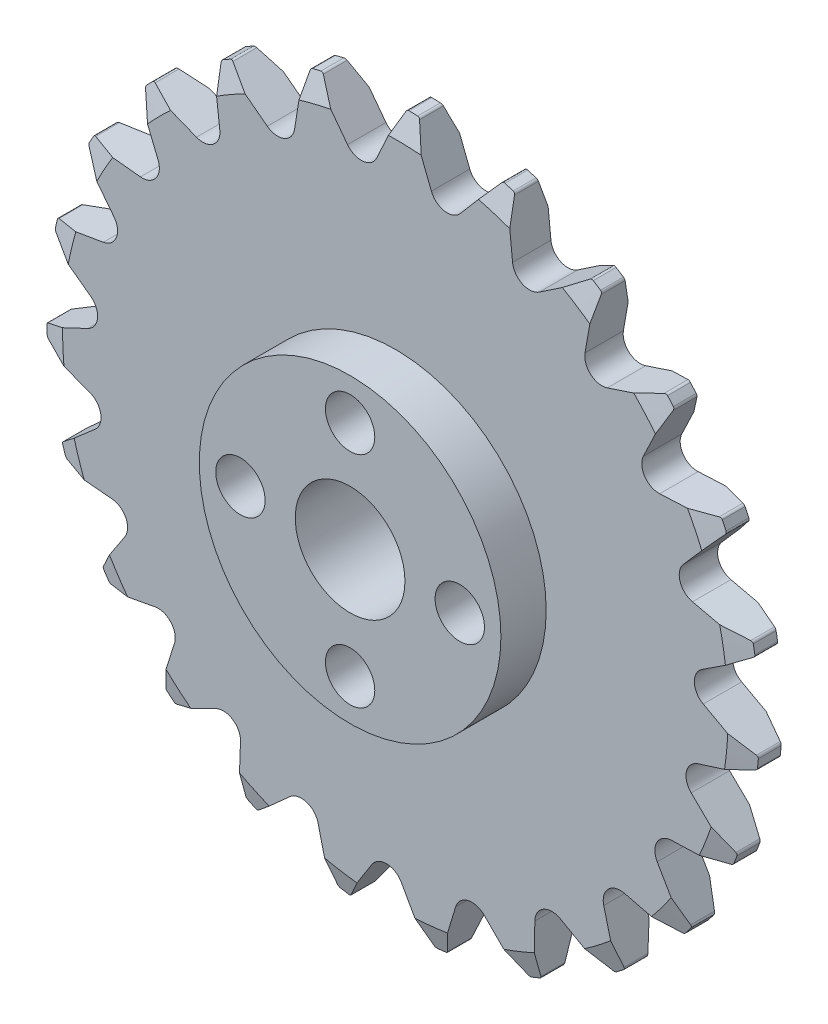
from build123d import *

# Parameters (mm, degrees)
SKETCH1_W                      = 26
SKETCH1_H                      = 2.7999944
CUT_EXTRUDE1_DEPTH             = 3.7999944
CUT_EXTRUDE2_DEPTH             = 3.7999944
CUT_EXTRUDE3_DEPTH             = 3.7999944
CUT_EXTRUDE4_DEPTH             = 3.7999944
CUT_EXTRUDE5_DEPTH             = 3.7999944
CUT_EXTRUDE6_DEPTH             = 3.7999944
CUT_EXTRUDE7_DEPTH             = 3.7999944
CUT_EXTRUDE8_DEPTH             = 3.7999944
CUT_EXTRUDE9_DEPTH             = 3.7999944
CUT_EXTRUDE10_DEPTH            = 3.7999944
CUT_EXTRUDE11_DEPTH            = 3.7999944
CUT_EXTRUDE12_DEPTH            = 3.7999944
CUT_EXTRUDE13_DEPTH            = 3.7999944
CUT_EXTRUDE14_DEPTH            = 3.7999944
CUT_EXTRUDE15_DEPTH            = 3.7999944
CUT_EXTRUDE16_DEPTH            = 3.7999944
CUT_EXTRUDE17_DEPTH            = 3.7999944
CUT_EXTRUDE18_DEPTH            = 3.7999944
CUT_EXTRUDE19_DEPTH            = 3.7999944
CUT_EXTRUDE20_DEPTH            = 3.7999944
CUT_EXTRUDE21_DEPTH            = 3.7999944
CUT_EXTRUDE22_DEPTH            = 3.7999944
CUT_EXTRUDE23_DEPTH            = 3.7999944
SKETCH25_W                     = 11
SKETCH25_H                     = 3.302
F_8_0_8_DIAMETER_HOLE1_D       = 8
F_8_0_8_DIAMETER_HOLE1_DEPTH   = 6.1019944
F_3_6_3_6_DIAMETER_HOLE1_D     = 3.6
F_3_6_3_6_DIAMETER_HOLE1_DEPTH = 6.1019944
F_3_6_3_6_DIAMETER_HOLE2_D     = 3.6
F_3_6_3_6_DIAMETER_HOLE2_DEPTH = 6.1019944
FILLET1_R                      = 0.2


with BuildPart() as part:
    # Sketch1 → Revolve1 (revolve)
    with BuildSketch(Plane(origin=(0, 0, 0), x_dir=(1, 0, 0), z_dir=(0, 1, 0))):
        with Locations((13, 1.3999972)):
            Rectangle(SKETCH1_W, SKETCH1_H)
    revolve(axis=Axis((0, 0, -2.7999944), (0, 0, 1)))

    # Sketch2 → Cut-Extrude1 (cut, through all)
    with BuildSketch(Plane(origin=(0, 0, -2.7999944), x_dir=(-1, 0, 0), z_dir=(0, 0, -1))):
        with BuildLine():
            Line((18.801313039, 17.958580902), (17.308486788, 14.31139503))
            ThreePointArc((17.308486788, 14.31139503), (17.465043178, 13.088273063), (18.595024492, 12.594634046))
            Line((18.595024492, 12.594634046), (22.514630462, 13.003515492))
            ThreePointArc((22.514630462, 13.003515492), (20.80600791, 15.591986238), (18.801313039, 17.958580902))
        make_face()
    extrude(amount=-CUT_EXTRUDE1_DEPTH, mode=Mode.SUBTRACT)

    # Sketch3 → Cut-Extrude2 (cut, through all)
    with BuildSketch(Plane(origin=(0, 0, -2.7999944), x_dir=(-1, 0, 0), z_dir=(0, 0, -1))):
        with BuildLine():
            Line((22.949276492, 12.220094456), (20.527809316, 9.110915831))
            ThreePointArc((20.527809316, 9.110915831), (20.348565813, 7.890912137), (21.303462141, 7.110713283))
            Line((21.303462141, 7.110713283), (25.188033384, 6.446935261))
            ThreePointArc((25.188033384, 6.446935261), (24.24113224, 9.400399338), (22.949276492, 12.220094456))
        make_face()
    extrude(amount=-CUT_EXTRUDE2_DEPTH, mode=Mode.SUBTRACT)

    # Sketch4 → Cut-Extrude3 (cut, through all)
    with BuildSketch(Plane(origin=(0, 0, -2.7999944), x_dir=(-1, 0, 0), z_dir=(0, 0, -1))):
        with BuildLine():
            Line((25.395197093, 5.575299507), (22.224678136, 3.234721685))
            ThreePointArc((22.224678136, 3.234721685), (21.72292841, 2.108318355), (22.431919461, 1.099423446))
            Line((22.431919461, 1.099423446), (25.993355097, -0.587784666))
            ThreePointArc((25.993355097, -0.587784666), (25.878402688, 2.511627823), (25.395197093, 5.575299507))
        make_face()
    extrude(amount=-CUT_EXTRUDE3_DEPTH, mode=Mode.SUBTRACT)

    # Sketch5 → Cut-Extrude4 (cut, through all)
    with BuildSketch(Plane(origin=(0, 0, -2.7999944), x_dir=(-1, 0, 0), z_dir=(0, 0, -1))):
        with BuildLine():
            Line((25.957672102, -1.482989902), (22.273244249, -2.881376971))
            ThreePointArc((22.273244249, -2.881376971), (21.486200783, -3.830639754), (21.896703933, -4.993405599))
            Line((21.896703933, -4.993405599), (24.870868574, -7.578911293))
            ThreePointArc((24.870868574, -7.578911293), (25.596390394, -4.563419638), (25.957672102, -1.482989902))
        make_face()
    extrude(amount=-CUT_EXTRUDE4_DEPTH, mode=Mode.SUBTRACT)

    # Sketch6 → Cut-Extrude5 (cut, through all)
    with BuildSketch(Plane(origin=(0, 0, -2.7999944), x_dir=(-1, 0, 0), z_dir=(0, 0, -1))):
        with BuildLine():
            Line((24.594985319, -8.431292733), (20.669905729, -8.783777078))
            ThreePointArc((20.669905729, -8.783777078), (19.655939936, -9.485496836), (19.737510045, -10.715896595))
            Line((19.737510045, -10.715896595), (21.903823506, -14.00794474))
            ThreePointArc((21.903823506, -14.00794474), (23.416010921, -11.30001914), (24.594985319, -8.431292733))
        make_face()
    extrude(amount=-CUT_EXTRUDE5_DEPTH, mode=Mode.SUBTRACT)

    # Sketch7 → Cut-Extrude6 (cut, through all)
    with BuildSketch(Plane(origin=(0, 0, -2.7999944), x_dir=(-1, 0, 0), z_dir=(0, 0, -1))):
        with BuildLine():
            Line((21.40820099, -14.754285153), (17.53357486, -14.034724622))
            ThreePointArc((17.53357486, -14.034724622), (16.367887944, -14.436858011), (16.11447533, -15.643638561))
            Line((16.11447533, -15.643638561), (17.312272051, -19.398073008))
            ThreePointArc((17.312272051, -19.398073008), (19.498973038, -17.198547917), (21.40820099, -14.754285153))
        make_face()
    extrude(amount=-CUT_EXTRUDE6_DEPTH, mode=Mode.SUBTRACT)

    # Sketch8 → Cut-Extrude7 (cut, through all)
    with BuildSketch(Plane(origin=(0, 0, -2.7999944), x_dir=(-1, 0, 0), z_dir=(0, 0, -1))):
        with BuildLine():
            Line((16.633668329, -19.98301974), (13.096858955, -18.244780846))
            ThreePointArc((13.096858955, -18.244780846), (11.865904582, -18.317503472), (11.296303699, -19.411163421))
            Line((11.296303699, -19.411163421), (11.436748577, -23.349534942))
            ThreePointArc((11.436748577, -23.349534942), (14.135785527, -21.821539073), (16.633668329, -19.98301974))
        make_face()
    extrude(amount=-CUT_EXTRUDE7_DEPTH, mode=Mode.SUBTRACT)

    # Sketch9 → Cut-Extrude8 (cut, through all)
    with BuildSketch(Plane(origin=(0, 0, -2.7999944), x_dir=(-1, 0, 0), z_dir=(0, 0, -1))):
        with BuildLine():
            Line((10.625492582, -23.729705169), (7.688808935, -21.101705139))
            ThreePointArc((7.688808935, -21.101705139), (6.48388136, -20.839623497), (5.6403369, -21.739051089))
            Line((5.6403369, -21.739051089), (4.713013781, -25.569268685))
            ThreePointArc((4.713013781, -25.569268685), (7.724211471, -24.826126503), (10.625492582, -23.729705169))
        make_face()
    extrude(amount=-CUT_EXTRUDE8_DEPTH, mode=Mode.SUBTRACT)

    # Sketch10 → Cut-Extrude9 (cut, through all)
    with BuildSketch(Plane(origin=(0, 0, -2.7999944), x_dir=(-1, 0, 0), z_dir=(0, 0, -1))):
        with BuildLine():
            Line((3.829272659, -25.716466921), (1.71051513, -22.393612495))
            ThreePointArc((1.71051513, -22.393612495), (0.620978318, -21.816163983), (-0.433947885, -22.454652788))
            Line((-0.433947885, -22.454652788), (-2.360263687, -25.892646742))
            ThreePointArc((-2.360263687, -25.892646742), (0.739767985, -25.989473702), (3.829272659, -25.716466921))
        make_face()
    extrude(amount=-CUT_EXTRUDE9_DEPTH, mode=Mode.SUBTRACT)

    # Sketch11 → Cut-Extrude10 (cut, through all)
    with BuildSketch(Plane(origin=(0, 0, -2.7999944), x_dir=(-1, 0, 0), z_dir=(0, 0, -1))):
        with BuildLine():
            Line((-3.250946899, -25.795955967), (-4.394639757, -22.024688057))
            ThreePointArc((-4.394639757, -22.024688057), (-5.287979844, -21.174699388), (-6.47604874, -21.504895613))
            Line((-6.47604874, -21.504895613), (-9.258491195, -24.295685642))
            ThreePointArc((-9.258491195, -24.295685642), (-6.299540707, -25.225300531), (-3.250946899, -25.795955967))
        make_face()
    extrude(amount=-CUT_EXTRUDE10_DEPTH, mode=Mode.SUBTRACT)

    # Sketch12 → Cut-Extrude11 (cut, through all)
    with BuildSketch(Plane(origin=(0, 0, -2.7999944), x_dir=(-1, 0, 0), z_dir=(0, 0, -1))):
        with BuildLine():
            Line((-10.090058599, -23.962276968), (-10.173864317, -20.022293262))
            ThreePointArc((-10.173864317, -20.022293262), (-10.804752732, -18.962804207), (-12.037850686, -18.960218709))
            Line((-12.037850686, -18.960218709), (-15.470058766, -20.896824682))
            ThreePointArc((-15.470058766, -20.896824682), (-12.871641284, -22.590282217), (-10.090058599, -23.962276968))
        make_face()
    extrude(amount=-CUT_EXTRUDE11_DEPTH, mode=Mode.SUBTRACT)

    # Sketch13 → Cut-Extrude12 (cut, through all)
    with BuildSketch(Plane(origin=(0, 0, -2.7999944), x_dir=(-1, 0, 0), z_dir=(0, 0, -1))):
        with BuildLine():
            Line((-16.18083681, -20.351425506), (-15.198539903, -16.534936571))
            ThreePointArc((-15.198539903, -16.534936571), (-15.520186538, -15.344524588), (-16.706860316, -15.00934912))
            Line((-16.706860316, -15.00934912), (-20.534282848, -15.948141832))
            ThreePointArc((-20.534282848, -15.948141832), (-18.489111111, -18.279846015), (-16.18083681, -20.351425506))
        make_face()
    extrude(amount=-CUT_EXTRUDE12_DEPTH, mode=Mode.SUBTRACT)

    # Sketch14 → Cut-Extrude13 (cut, through all)
    with BuildSketch(Plane(origin=(0, 0, -2.7999944), x_dir=(-1, 0, 0), z_dir=(0, 0, -1))):
        with BuildLine():
            Line((-21.071556378, -15.231201916), (-19.096009313, -11.821259277))
            ThreePointArc((-19.096009313, -11.821259277), (-19.084559109, -10.588211776), (-20.136798545, -9.94530477))
            Line((-20.136798545, -9.94530477), (-24.07557311, -9.816658261))
            ThreePointArc((-24.07557311, -9.816658261), (-22.735328148, -12.613677259), (-21.071556378, -15.231201916))
        make_face()
    extrude(amount=-CUT_EXTRUDE13_DEPTH, mode=Mode.SUBTRACT)

    # Sketch15 → Cut-Extrude14 (cut, through all)
    with BuildSketch(Plane(origin=(0, 0, -2.7999944), x_dir=(-1, 0, 0), z_dir=(0, 0, -1))):
        with BuildLine():
            Line((-24.399495006, -8.981349757), (-21.577215071, -6.230853262))
            ThreePointArc((-21.577215071, -6.230853262), (-21.233517237, -5.046619734), (-22.073282546, -4.143662662))
            Line((-22.073282546, -4.143662662), (-25.831288253, -2.957118055))
            ThreePointArc((-25.831288253, -2.957118055), (-25.295369904, -6.012009764), (-24.399495006, -8.981349757))
        make_face()
    extrude(amount=-CUT_EXTRUDE14_DEPTH, mode=Mode.SUBTRACT)

    # Sketch16 → Cut-Extrude15 (cut, through all)
    with BuildSketch(Plane(origin=(0, 0, -2.7999944), x_dir=(-1, 0, 0), z_dir=(0, 0, -1))):
        with BuildLine():
            Line((-25.917834709, -2.065391975), (-22.458137497, -0.178333364))
            ThreePointArc((-22.458137497, -0.178333364), (-21.807682528, 0.869257006), (-22.372692159, 1.965295949))
            Line((-22.372692159, 1.965295949), (-25.671214916, 4.12173807))
            ThreePointArc((-25.671214916, 4.12173807), (-25.979369793, 1.035540992), (-25.917834709, -2.065391975))
        make_face()
    extrude(amount=-CUT_EXTRUDE15_DEPTH, mode=Mode.SUBTRACT)

    # Sketch17 → Cut-Extrude16 (cut, through all)
    with BuildSketch(Plane(origin=(0, 0, -2.7999944), x_dir=(-1, 0, 0), z_dir=(0, 0, -1))):
        with BuildLine():
            Line((-25.513967178, 5.003746482), (-21.673442603, 5.887412704))
            ThreePointArc((-21.673442603, 5.887412704), (-20.76447177, 6.720664931), (-21.012821543, 7.928497551))
            Line((-21.012821543, 7.928497551), (-23.607225007, 10.894903738))
            ThreePointArc((-23.607225007, 10.894903738), (-24.736598672, 8.00629041), (-25.513967178, 5.003746482))
        make_face()
    extrude(amount=-CUT_EXTRUDE16_DEPTH, mode=Mode.SUBTRACT)

    # Sketch18 → Cut-Extrude17 (cut, through all)
    with BuildSketch(Plane(origin=(0, 0, -2.7999944), x_dir=(-1, 0, 0), z_dir=(0, 0, -1))):
        with BuildLine():
            Line((-23.21784542, 11.701779953), (-19.281327621, 11.516516304))
            ThreePointArc((-19.281327621, 11.516516304), (-18.181255132, 12.073631883), (-18.09452608, 13.30367876))
            Line((-18.09452608, 13.30367876), (-19.792395215, 16.860044236))
            ThreePointArc((-19.792395215, 16.860044236), (-21.65922719, 14.383249894), (-23.21784542, 11.701779953))
        make_face()
    extrude(amount=-CUT_EXTRUDE17_DEPTH, mode=Mode.SUBTRACT)

    # Sketch19 → Cut-Extrude18 (cut, through all)
    with BuildSketch(Plane(origin=(0, 0, -2.7999944), x_dir=(-1, 0, 0), z_dir=(0, 0, -1))):
        with BuildLine():
            Line((-19.199762281, 17.531945937), (-15.459204775, 16.291492575))
            ThreePointArc((-15.459204775, 16.291492575), (-14.249617974, 16.531152791), (-13.834242395, 17.692186975))
            Line((-13.834242395, 17.692186975), (-14.509654015, 21.574752383))
            ThreePointArc((-14.509654015, 21.574752383), (-16.975489912, 19.693469533), (-19.199762281, 17.531945937))
        make_face()
    extrude(amount=-CUT_EXTRUDE18_DEPTH, mode=Mode.SUBTRACT)

    # Sketch20 → Cut-Extrude19 (cut, through all)
    with BuildSketch(Plane(origin=(0, 0, -2.7999944), x_dir=(-1, 0, 0), z_dir=(0, 0, -1))):
        with BuildLine():
            Line((-13.757720608, 22.061847694), (-10.490543432, 19.85820337))
            ThreePointArc((-10.490543432, 19.85820337), (-9.261151839, 19.762633722), (-8.547936239, 20.768546619))
            Line((-8.547936239, 20.768546619), (-8.150798153, 24.689359843))
            ThreePointArc((-8.150798153, 24.689359843), (-11.032758204, 23.543114628), (-13.757720608, 22.061847694))
        make_face()
    extrude(amount=-CUT_EXTRUDE19_DEPTH, mode=Mode.SUBTRACT)

    # Sketch21 → Cut-Extrude20 (cut, through all)
    with BuildSketch(Plane(origin=(0, 0, -2.7999944), x_dir=(-1, 0, 0), z_dir=(0, 0, -1))):
        with BuildLine():
            Line((-7.295331734, 24.955523134), (-4.743846474, 21.952122067))
            ThreePointArc((-4.743846474, 21.952122067), (-3.585828439, 21.528410517), (-2.627668756, 22.30459817))
            Line((-2.627668756, 22.30459817), (-1.187434879, 25.972870431))
            ThreePointArc((-1.187434879, 25.972870431), (-4.271777292, 25.646674614), (-7.295331734, 24.955523134))
        make_face()
    extrude(amount=-CUT_EXTRUDE20_DEPTH, mode=Mode.SUBTRACT)

    # Sketch22 → Cut-Extrude21 (cut, through all)
    with BuildSketch(Plane(origin=(0, 0, -2.7999944), x_dir=(-1, 0, 0), z_dir=(0, 0, -1))):
        with BuildLine():
            Line((-0.29188148, 25.998361587), (1.354679875, 22.417952294))
            ThreePointArc((1.354679875, 22.417952294), (2.355439453, 21.697523591), (3.487480897, 22.186419711))
            Line((3.487480897, 22.186419711), (5.863995007, 25.330092036))
            ThreePointArc((5.863995007, 25.330092036), (2.806021799, 25.84813807), (-0.29188148, 25.998361587))
        make_face()
    extrude(amount=-CUT_EXTRUDE21_DEPTH, mode=Mode.SUBTRACT)

    # Sketch23 → Cut-Extrude22 (cut, through all)
    with BuildSketch(Plane(origin=(0, 0, -2.7999944), x_dir=(-1, 0, 0), z_dir=(0, 0, -1))):
        with BuildLine():
            Line((6.733216289, 25.113020495), (7.352735815, 21.221145554))
            ThreePointArc((7.352735815, 21.221145554), (8.122015175, 20.257430599), (9.343980047, 20.422775999))
            Line((9.343980047, 20.422775999), (12.48051921, 22.808696593))
            ThreePointArc((12.48051921, 22.808696593), (9.675711091, 24.132563372), (6.733216289, 25.113020495))
        make_face()
    extrude(amount=-CUT_EXTRUDE22_DEPTH, mode=Mode.SUBTRACT)

    # Sketch24 → Cut-Extrude23 (cut, through all)
    with BuildSketch(Plane(origin=(0, 0, -2.7999944), x_dir=(-1, 0, 0), z_dir=(0, 0, -1))):
        with BuildLine():
            Line((13.258942208, 22.365161558), (12.805472976, 18.45046353))
            ThreePointArc((12.805472976, 18.45046353), (13.286218188, 17.314936652), (14.507478942, 17.144468418))
            Line((14.507478942, 17.144468418), (18.171420397, 18.595684466))
            ThreePointArc((18.171420397, 18.595684466), (15.827797154, 20.627186848), (13.258942208, 22.365161558))
        make_face()
    extrude(amount=-CUT_EXTRUDE23_DEPTH, mode=Mode.SUBTRACT)

    # Sketch25 → Revolve2 (revolve)
    with BuildSketch(Plane(origin=(0, 0, 0), x_dir=(1, 0, 0), z_dir=(0, 1, 0))):
        with Locations((5.5, -1.651)):
            Rectangle(SKETCH25_W, SKETCH25_H)
    revolve(axis=Axis((0, 0, 0), (0, 0, 1)))

    # Ø8.0 (8) Diameter Hole1
    with Locations(Plane.XY.offset(3.302)):
        with Locations((0, 0)):
            Hole(F_8_0_8_DIAMETER_HOLE1_D / 2, depth=F_8_0_8_DIAMETER_HOLE1_DEPTH)

    # Ø3.6 (3.6) Diameter Hole1
    with Locations(Plane.XY.offset(3.302)):
        with Locations((0, 8), (-8, 0), (0, -8)):
            Hole(F_3_6_3_6_DIAMETER_HOLE1_D / 2, depth=F_3_6_3_6_DIAMETER_HOLE1_DEPTH)

    # Ø3.6 (3.6) Diameter Hole2
    with Locations(Plane(origin=(0, 0, -2.7999944), x_dir=(-1, 0, 0), z_dir=(0, 0, -1))):
        with Locations((-8, 0)):
            Hole(F_3_6_3_6_DIAMETER_HOLE2_D / 2, depth=F_3_6_3_6_DIAMETER_HOLE2_DEPTH)

    # Fillet1
    fillet1_edges = [part.edges().sort_by_distance(p)[0] for p in [
        (-16.633668329, -19.98301974, -1.3999972),
        (-11.436748577, -23.349534942, -1.3999972),
        (-10.625492582, -23.729705169, -1.3999972),
        (-4.713013781, -25.569268685, -1.3999972),
        (-18.801313039, 17.958580902, -1.3999972),
        (-22.514630462, 13.003515492, -1.3999972),
        (-3.829272659, -25.716466921, -1.3999972),
        (2.360263687, -25.892646742, -1.3999972),
        (3.250946899, -25.795955967, -1.3999972),
        (9.258491195, -24.295685642, -1.3999972),
        (10.090058599, -23.962276968, -1.3999972),
        (15.470058766, -20.896824682, -1.3999972),
        (16.18083681, -20.351425506, -1.3999972),
        (20.534282848, -15.948141832, -1.3999972),
        (21.071556378, -15.231201916, -1.3999972),
        (24.07557311, -9.816658261, -1.3999972),
        (24.399495006, -8.981349757, -1.3999972),
        (25.831288253, -2.957118055, -1.3999972),
        (25.917834709, -2.065391975, -1.3999972),
        (25.671214916, 4.12173807, -1.3999972),
        (25.513967178, 5.003746482, -1.3999972),
        (23.607225007, 10.894903738, -1.3999972),
        (23.21784542, 11.701779953, -1.3999972),
        (19.792395215, 16.860044236, -1.3999972),
        (-22.949276492, 12.220094456, -1.3999972),
        (-25.188033384, 6.446935261, -1.3999972),
        (19.199762281, 17.531945937, -1.3999972),
        (14.509654015, 21.574752383, -1.3999972),
        (13.757720608, 22.061847694, -1.3999972),
        (8.150798153, 24.689359843, -1.3999972),
        (7.295331734, 24.955523134, -1.3999972),
        (1.187434879, 25.972870431, -1.3999972),
        (0.29188148, 25.998361587, -1.3999972),
        (-5.863995007, 25.330092036, -1.3999972),
        (-6.733216289, 25.113020495, -1.3999972),
        (-12.48051921, 22.808696593, -1.3999972),
        (-13.258942208, 22.365161558, -1.3999972),
        (-18.171420397, 18.595684466, -1.3999972),
        (-25.395197093, 5.575299507, -1.3999972),
        (-25.993355097, -0.587784666, -1.3999972),
        (-25.957672102, -1.482989902, -1.3999972),
        (-24.870868574, -7.578911293, -1.3999972),
        (-24.594985319, -8.431292733, -1.3999972),
        (-21.903823506, -14.00794474, -1.3999972),
        (-21.40820099, -14.754285153, -1.3999972),
        (-17.312272051, -19.398073008, -1.3999972),
    ]]
    fillet(fillet1_edges, radius=FILLET1_R)

    # Sketch32 → Cut-Revolve1 (revolve, cut)
    with BuildSketch(Plane(origin=(0, 0, 0), x_dir=(0, 0, -1), z_dir=(1, 0, 0))):
        Polygon((0, 24.2697), (0, 26.0477), (0.5842, 26.0477), align=None)
        Polygon((2.2157944, 26.0477), (2.7999944, 24.2697), (2.7999944, 26.0477), align=None)
    revolve(axis=Axis((0, 0, 0), (0, 0, -1)), mode=Mode.SUBTRACT)


solid = part.part
